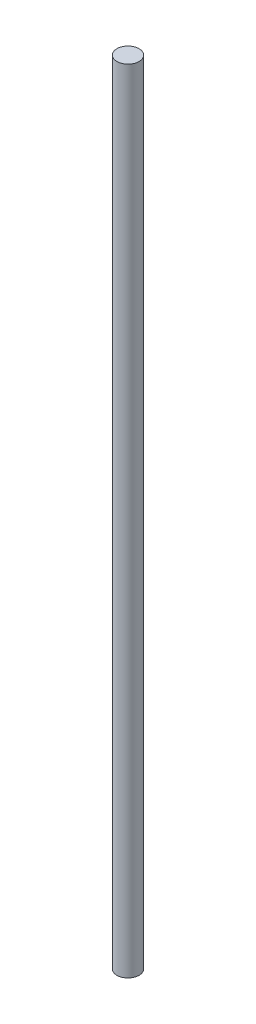
from build123d import *

# Parameters (mm, degrees)
CROQUIS6_R              = 4
SALIENTE_EXTRUIR5_DEPTH = 285


with BuildPart() as part:
    # Croquis6 → Saliente-Extruir5 (new body)
    with BuildSketch(Plane(origin=(0, 0, 0), x_dir=(1, 0, 0), z_dir=(0, 1, 0))):
        with Locations((-22, -35)):
            Circle(CROQUIS6_R)
    extrude(amount=-SALIENTE_EXTRUIR5_DEPTH)


solid = part.part
